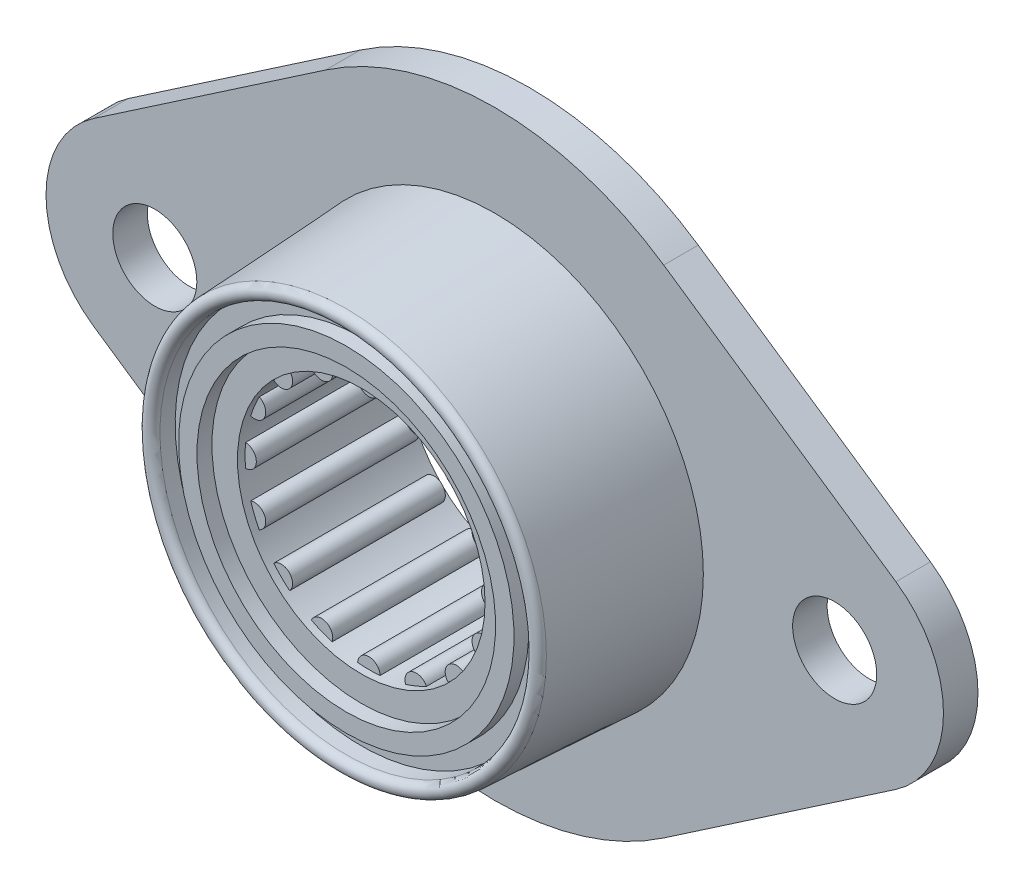
from build123d import *
from build123d.topology import SkipClean

# Parameters (mm, degrees)
SKETCH1_R          = 2.8
SKETCH1_R_2        = 13.9
EXTRUDE1_DEPTH     = 2.3
CUT_EXTRUDE2_DEPTH = 38.67372281
SKETCH4_R          = 8.25
CUT_EXTRUDE3_DEPTH = 0.508
CUT_EXTRUDE4_START = -0.508
SKETCH5_R          = 8.25
CUT_EXTRUDE4_DEPTH = 0.508


with BuildPart() as part:
    # Sketch1 → Extrude1 (new body)
    with BuildSketch(Plane.XY):
        with BuildLine():
            Line((-26.731125828, 5.992237644), (-11.258278146, 16.530310741))
            ThreePointArc((-11.258278146, 16.530310741), (0, 20), (11.258278146, 16.530310741))
            Line((11.258278146, 16.530310741), (26.731125828, 5.992237644))
            ThreePointArc((26.731125828, 5.992237644), (29.9, 0), (26.731125828, -5.992237644))
            Line((26.731125828, -5.992237644), (11.258278146, -16.530310741))
            ThreePointArc((11.258278146, -16.530310741), (0, -20), (-11.258278146, -16.530310741))
            Line((-11.258278146, -16.530310741), (-26.731125828, -5.992237644))
            ThreePointArc((-26.731125828, -5.992237644), (-29.9, 0), (-26.731125828, 5.992237644))
        make_face()
        with Locations((-22.65, 0)):
            Circle(SKETCH1_R, mode=Mode.SUBTRACT)
        with Locations((22.65, 0)):
            Circle(SKETCH1_R, mode=Mode.SUBTRACT)
        Circle(SKETCH1_R_2, mode=Mode.SUBTRACT)
    extrude(amount=EXTRUDE1_DEPTH)

    # Sketch2 → Revolve1 (revolve)
    with BuildSketch(Plane(origin=(0, 0, 0), x_dir=(0, 0, -1), z_dir=(1, 0, 0))):
        with BuildLine():
            Line((0, 13.9), (-2.3, 13.9))
            Line((-2.3, 13.9), (-12.235380244, 13.379308785))
            ThreePointArc((-12.235380244, 13.379308785), (-12.565356828, 13.227187496), (-12.7, 12.889701721))
            ThreePointArc((-12.7, 12.889701721), (-12.556400613, 12.543022133), (-12.209721025, 12.399422746))
            Line((-12.209721025, 12.399422746), (-11.193721025, 12.399422746))
            Line((-11.193721025, 12.399422746), (-11.193721025, 11.17456706))
            Line((-11.193721025, 11.17456706), (-12.192, 11.17456706))
            Line((-12.192, 11.17456706), (-12.192, 9.949711373))
            Line((-12.192, 9.949711373), (-11.193721025, 9.949711373))
            Line((-11.193721025, 9.949711373), (-11.193721025, 8.724855687))
            Line((-11.193721025, 8.724855687), (-11.193721025, 7.5))
            Line((-11.193721025, 7.5), (0, 7.5))
            Line((0, 7.5), (0, 13.9))
        make_face()
    revolve(axis=Axis((0, 0, 0), (0, 0, 1)))

    # Sketch3 → Cut-Extrude2 (cut, through all)
    with BuildSketch(Plane.XY.offset(11.193721025)):
        with BuildLine():
            ThreePointArc((-3.836285754, 7.30379433), (-4.583454422, 6.859624301), (-5.279743091, 6.339306973))
            ThreePointArc((-5.279743091, 6.339306973), (-5.303300859, 5.303300859), (-6.339306973, 5.279743091))
            ThreePointArc((-6.339306973, 5.279743091), (-6.859624301, 4.583454422), (-7.30379433, 3.836285754))
            ThreePointArc((-7.30379433, 3.836285754), (-6.929096494, 2.870125743), (-7.87722617, 2.451898827))
            ThreePointArc((-7.87722617, 2.451898827), (-8.091478563, 1.609495157), (-8.215909091, 0.749224806))
            ThreePointArc((-8.215909091, 0.749224806), (-7.5, 0), (-8.215909091, -0.749224806))
            ThreePointArc((-8.215909091, -0.749224806), (-8.091478563, -1.609495157), (-7.87722617, -2.451898827))
            ThreePointArc((-7.87722617, -2.451898827), (-6.929096494, -2.870125743), (-7.30379433, -3.836285754))
            ThreePointArc((-7.30379433, -3.836285754), (-6.859624301, -4.583454422), (-6.339306973, -5.279743091))
            ThreePointArc((-6.339306973, -5.279743091), (-5.303300859, -5.303300859), (-5.279743091, -6.339306973))
            ThreePointArc((-5.279743091, -6.339306973), (-4.583454422, -6.859624301), (-3.836285754, -7.30379433))
            ThreePointArc((-3.836285754, -7.30379433), (-2.870125743, -6.929096494), (-2.451898827, -7.87722617))
            ThreePointArc((-2.451898827, -7.87722617), (-1.609495157, -8.091478563), (-0.749224806, -8.215909091))
            ThreePointArc((-0.749224806, -8.215909091), (0, -7.5), (0.749224806, -8.215909091))
            ThreePointArc((0.749224806, -8.215909091), (1.609495157, -8.091478563), (2.451898827, -7.87722617))
            ThreePointArc((2.451898827, -7.87722617), (2.870125743, -6.929096494), (3.836285754, -7.30379433))
            ThreePointArc((3.836285754, -7.30379433), (4.583454422, -6.859624301), (5.279743091, -6.339306973))
            ThreePointArc((5.279743091, -6.339306973), (5.303300859, -5.303300859), (6.339306973, -5.279743091))
            ThreePointArc((6.339306973, -5.279743091), (6.859624301, -4.583454422), (7.30379433, -3.836285754))
            ThreePointArc((7.30379433, -3.836285754), (6.929096494, -2.870125743), (7.87722617, -2.451898827))
            ThreePointArc((7.87722617, -2.451898827), (8.091478563, -1.609495157), (8.215909091, -0.749224806))
            ThreePointArc((8.215909091, -0.749224806), (7.5, 0), (8.215909091, 0.749224806))
            ThreePointArc((8.215909091, 0.749224806), (8.091478563, 1.609495157), (7.87722617, 2.451898827))
            ThreePointArc((7.87722617, 2.451898827), (6.929096494, 2.870125743), (7.30379433, 3.836285754))
            ThreePointArc((7.30379433, 3.836285754), (6.859624301, 4.583454422), (6.339306973, 5.279743091))
            ThreePointArc((6.339306973, 5.279743091), (5.303300859, 5.303300859), (5.279743091, 6.339306973))
            ThreePointArc((5.279743091, 6.339306973), (4.583454422, 6.859624301), (3.836285754, 7.30379433))
            ThreePointArc((3.836285754, 7.30379433), (2.870125743, 6.929096494), (2.451898827, 7.87722617))
            ThreePointArc((2.451898827, 7.87722617), (1.609495157, 8.091478563), (0.749224806, 8.215909091))
            ThreePointArc((0.749224806, 8.215909091), (0, 7.5), (-0.749224806, 8.215909091))
            ThreePointArc((-0.749224806, 8.215909091), (-1.609495157, 8.091478563), (-2.451898827, 7.87722617))
            ThreePointArc((-2.451898827, 7.87722617), (-2.870125743, 6.929096494), (-3.836285754, 7.30379433))
        make_face()
    extrude(amount=-CUT_EXTRUDE2_DEPTH, mode=Mode.SUBTRACT)

    # Sketch4 → Cut-Extrude3 (cut)
    with BuildSketch(Plane.XY.offset(11.193721025)):
        Circle(SKETCH4_R)
    extrude(amount=-CUT_EXTRUDE3_DEPTH, mode=Mode.SUBTRACT)

    # Sketch5 → Cut-Extrude4 (cut)
    with SkipClean():  # the faces are left unmerged after this step: merging them gives an invalid solid
        with BuildSketch(Plane(origin=(0, 0, 0), x_dir=(-1, 0, 0), z_dir=(0, 0, -1)).offset(CUT_EXTRUDE4_START)):
            Circle(SKETCH5_R)
        extrude(amount=CUT_EXTRUDE4_DEPTH, mode=Mode.SUBTRACT)


solid = part.part
